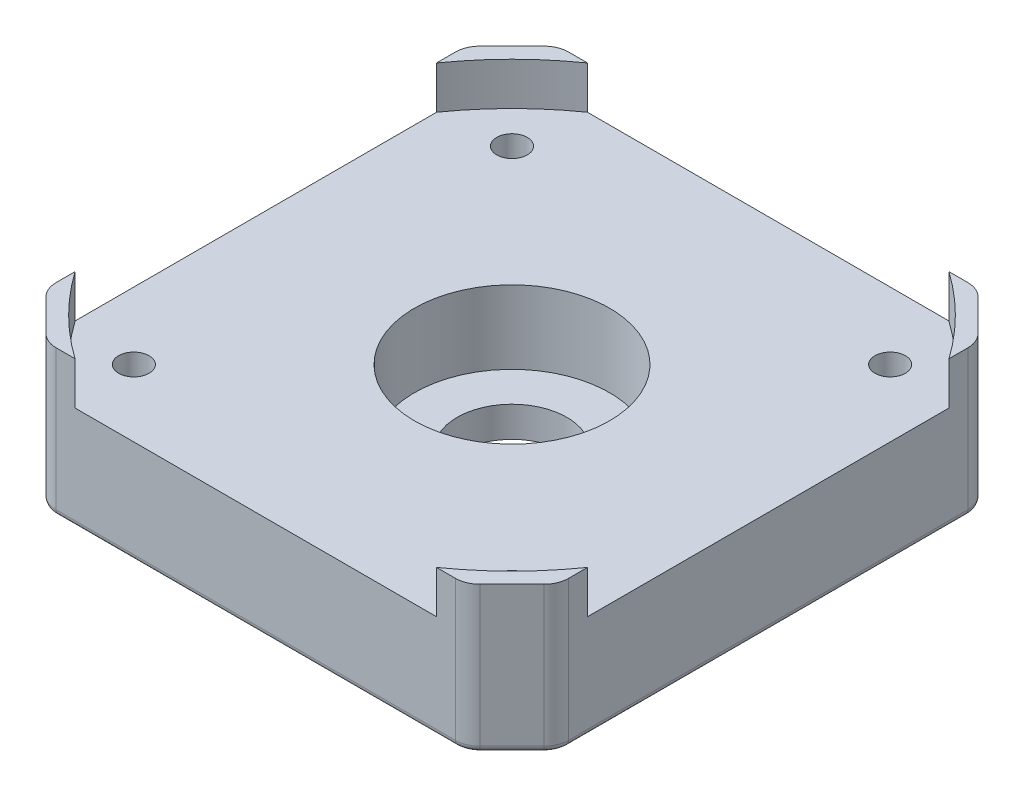
from build123d import *

# Parameters (mm, degrees)
SKETCH_1_R          = 1.25
SKETCH_1_R_2        = 4.5
EXTRUDE_1_DEPTH     = 8.5
EXTRUDE_2_DEPTH     = 12
CHAMFER_1_SIZE      = 2.5
SKETCH_2_R          = 8
CUT_EXTRUDE_1_DEPTH = 6
FILLET_1_R          = 2
FILLET_2_R          = 0.5


with BuildPart() as part:
    # Эскиз1 → Бобышка-Вытянуть1 (new body)
    with BuildSketch(Plane(origin=(0, 0, 0), x_dir=(1, 0, 0), z_dir=(0, 1, 0))):
        with BuildLine():
            ThreePointArc((-14.815194903, 21), (-18.172644276, 18.172644276), (-21, 14.815194903))
            Line((-21, 14.815194903), (-21, -14.815194903))
            ThreePointArc((-21, -14.815194903), (-18.172644276, -18.172644276), (-14.815194903, -21))
            Line((-14.815194903, -21), (14.815194903, -21))
            ThreePointArc((14.815194903, -21), (18.172644276, -18.172644276), (21, -14.815194903))
            Line((21, -14.815194903), (21, 14.815194903))
            ThreePointArc((21, 14.815194903), (18.172644276, 18.172644276), (14.815194903, 21))
            Line((14.815194903, 21), (-14.815194903, 21))
        make_face()
        with Locations((-15.5, -15.5)):
            Circle(SKETCH_1_R, mode=Mode.SUBTRACT)
        with Locations((15.5, -15.5)):
            Circle(SKETCH_1_R, mode=Mode.SUBTRACT)
        with Locations((-15.5, 15.5)):
            Circle(SKETCH_1_R, mode=Mode.SUBTRACT)
        with Locations((15.5, 15.5)):
            Circle(SKETCH_1_R, mode=Mode.SUBTRACT)
        Circle(SKETCH_1_R_2, mode=Mode.SUBTRACT)
    extrude(amount=EXTRUDE_1_DEPTH)

    # Эскиз1<4> → Бобышка-Вытянуть2 (add)
    with BuildSketch(Plane(origin=(0, 0, 0), x_dir=(1, 0, 0), z_dir=(0, 1, 0))):
        with BuildLine():
            Line((-17.2, 21), (-21, 17.2))
            Line((-21, 17.2), (-21, 14.815194903))
            ThreePointArc((-21, 14.815194903), (-18.172644276, 18.172644276), (-14.815194903, 21))
            Line((-14.815194903, 21), (-17.2, 21))
        make_face()
        with BuildLine():
            ThreePointArc((-14.815194903, -21), (-18.172644276, -18.172644276), (-21, -14.815194903))
            Line((-21, -14.815194903), (-21, -17.2))
            Line((-21, -17.2), (-17.2, -21))
            Line((-17.2, -21), (-14.815194903, -21))
        make_face()
        with BuildLine():
            Line((17.2, 21), (14.815194903, 21))
            ThreePointArc((14.815194903, 21), (18.172644276, 18.172644276), (21, 14.815194903))
            Line((21, 14.815194903), (21, 17.2))
            Line((21, 17.2), (17.2, 21))
        make_face()
        with BuildLine():
            ThreePointArc((21, -14.815194903), (18.172644276, -18.172644276), (14.815194903, -21))
            Line((14.815194903, -21), (17.2, -21))
            Line((17.2, -21), (21, -17.2))
            Line((21, -17.2), (21, -14.815194903))
        make_face()
    extrude(amount=EXTRUDE_2_DEPTH)

    # Фаска1
    chamfer_1_edges = [part.edges().sort_by_distance(p)[0] for p in [
        (-16.75, 0, -15.5),
        (14.25, 0, -15.5),
        (14.25, 0, 15.5),
        (-16.75, 0, 15.5),
    ]]
    chamfer(chamfer_1_edges, length=CHAMFER_1_SIZE)

    # Эскиз2 → Вырез-Вытянуть1 (cut)
    with BuildSketch(Plane(origin=(0, 8.5, 0), x_dir=(1, 0, 0), z_dir=(0, 1, 0))):
        Circle(SKETCH_2_R)
    extrude(amount=-CUT_EXTRUDE_1_DEPTH, mode=Mode.SUBTRACT)

    # Скругление1
    fillet_1_edges = [part.edges().sort_by_distance(p)[0] for p in [
        (21, 6, 17.2),
        (17.2, 6, 21),
        (-17.2, 6, 21),
        (-21, 6, 17.2),
        (-21, 6, -17.2),
        (-17.2, 6, -21),
        (17.2, 6, -21),
        (21, 6, -17.2),
    ]]
    fillet(fillet_1_edges, radius=FILLET_1_R)

    # Скругление2
    fillet_2_edges = [part.edges().sort_by_distance(p)[0] for p in [
        (-17.13693974, 0, 20.847759065),
        (-19.1, 0, 19.1),
        (-20.847759065, 0, 17.13693974),
        (-21, 0, 0),
        (-20.847759065, 0, -17.13693974),
        (-19.1, 0, -19.1),
        (-17.13693974, 0, -20.847759065),
        (0, 0, -21),
        (17.13693974, 0, -20.847759065),
        (19.1, 0, -19.1),
        (20.847759065, 0, -17.13693974),
        (21, 0, 0),
        (20.847759065, 0, 17.13693974),
        (19.1, 0, 19.1),
        (17.13693974, 0, 20.847759065),
        (0, 0, 21),
    ]]
    fillet(fillet_2_edges, radius=FILLET_2_R)


solid = part.part
